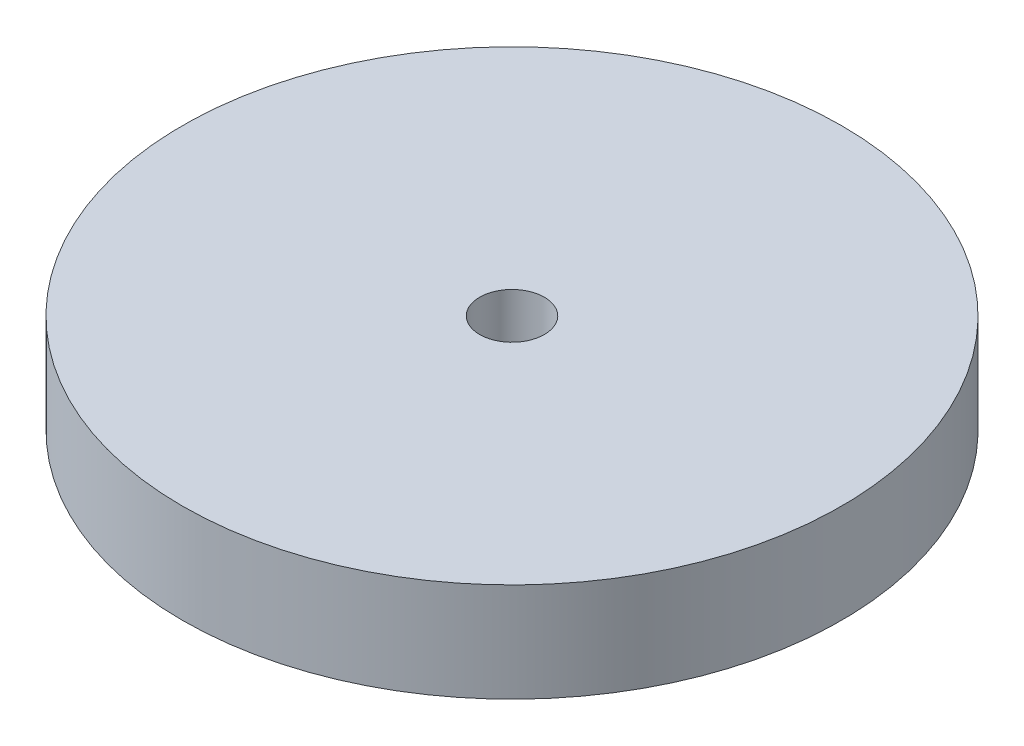
from build123d import *

# Parameters (mm, degrees)
SKETCH1_R           = 25.373140213
BOSS_EXTRUDE1_DEPTH = 7.62
SKETCH2_R           = 2.492289626
CUT_EXTRUDE1_DEPTH  = 7.62


with BuildPart() as part:
    # Sketch1 → Boss-Extrude1 (new body)
    with BuildSketch(Plane(origin=(0, 0, 0), x_dir=(1, 0, 0), z_dir=(0, 1, 0))):
        Circle(SKETCH1_R)
    extrude(amount=BOSS_EXTRUDE1_DEPTH)

    # Sketch2 → Cut-Extrude1 (cut)
    with BuildSketch(Plane(origin=(0, 7.62, 0), x_dir=(1, 0, 0), z_dir=(0, 1, 0))):
        Circle(SKETCH2_R)
    extrude(amount=-CUT_EXTRUDE1_DEPTH, mode=Mode.SUBTRACT)


solid = part.part
